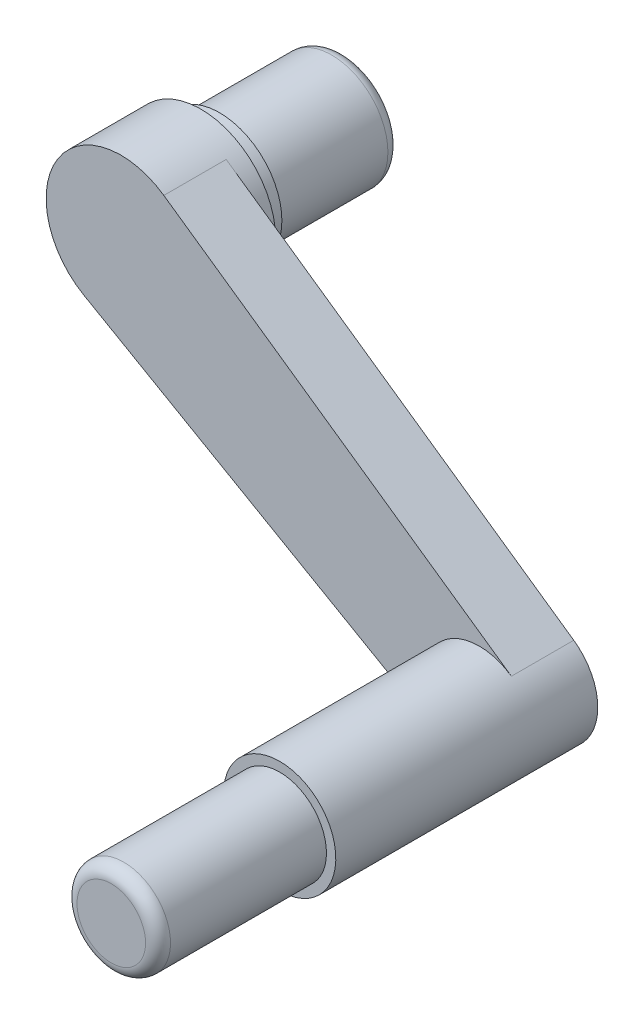
from build123d import *

# Parameters (mm, degrees)
Y_KSEKLIK_EKSTR_ZYON2_DEPTH = 50
IZIM3_R                     = 45
Y_KSEKLIK_EKSTR_ZYON3_DEPTH = 210
IZIM4_R                     = 37.5
Y_KSEKLIK_EKSTR_ZYON4_DEPTH = 135
RADYUS1_R                   = 10


with BuildPart() as part:
    # Çizim1 → Döndür1 (revolve)
    with BuildSketch(Plane(origin=(0, 0, 0), x_dir=(0, 0, -1), z_dir=(1, 0, 0)), mode=Mode.PRIVATE) as d_nd_r1_sk:
        Polygon((0, 0), (0, 60), (64, 60), (64, 50), (79, 50), (79, 45), (179, 45), (179, 0), align=None)
    revolve(d_nd_r1_sk.sketch.rotate(Axis((0, 0, 55.580802483), (0, 0, -1)), 90), axis=Axis((0, 0, 55.580802483), (0, 0, -1)))

    # Çizim2 → Yükseklik-Ekstrüzyon2 (add)
    with BuildSketch(Plane.XY):
        with BuildLine():
            Line((34.344942753, 49.19781405), (312.984226436, -145.319979709))
            ThreePointArc((312.984226436, -145.319979709), (325.22389765, -206.324838294), (264.818131867, -221.242806741))
            Line((264.818131867, -221.242806741), (-29.876516673, -52.032621993))
            Line((-29.876516673, -52.032621993), (34.344942753, 49.19781405))
        make_face()
    extrude(amount=-Y_KSEKLIK_EKSTR_ZYON2_DEPTH)

    # Çizim3 → Yükseklik-Ekstrüzyon3 (add)
    with BuildSketch(Plane(origin=(0, 0, -50), x_dir=(-1, 0, 0), z_dir=(0, 0, -1))):
        with Locations(Location((-287.225519371, -182.218340246, 0), (0, 0, 124.918853114))):
            Circle(IZIM3_R)
    extrude(amount=-Y_KSEKLIK_EKSTR_ZYON3_DEPTH)

    # Çizim4 → Yükseklik-Ekstrüzyon4 (add)
    with BuildSketch(Plane.XY.offset(160)):
        with Locations((287.225519371, -182.218340246)):
            Circle(IZIM4_R)
    extrude(amount=Y_KSEKLIK_EKSTR_ZYON4_DEPTH)

    # Radyus1
    radyus1_edges = [part.edges().sort_by_distance(p)[0] for p in [
        (249.725519371, -182.218340246, 295),
        (-45, 0, -179),
    ]]
    fillet(radyus1_edges, radius=RADYUS1_R)


solid = part.part
